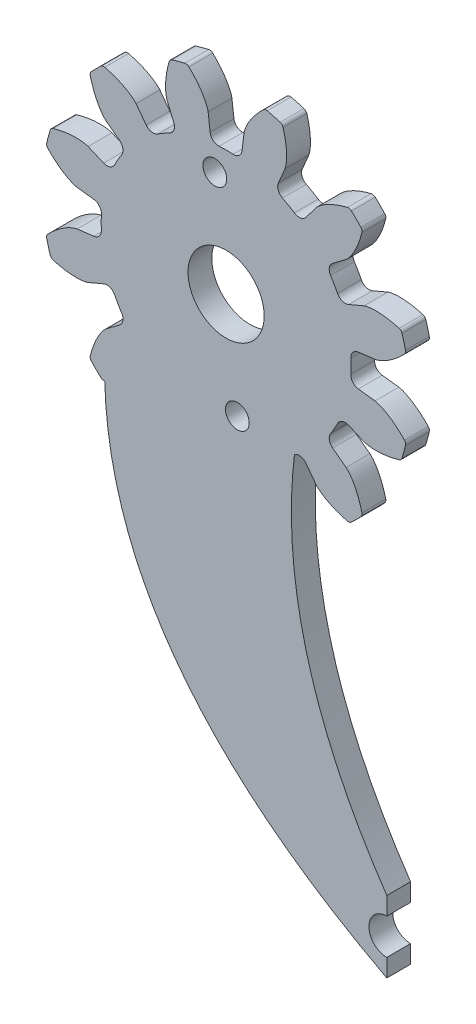
from build123d import *

# Parameters (mm, degrees)
SKETCH1_R                                 = 15.460869565
BOSS_EXTRUDE1_DEPTH                       = 2.00000108
CUT_EXTRUDE_DCLTBC_DEPTH                  = 3.00000108
FILLET_TIP_DCLTBC_R                       = 0.361402518
FILLET_ROOT_DCLTBC_R                      = 0.722805036
CIRPATTERN_DCLTBC_COUNT                   = 12
FILLET_TIP_DCLTBC_OF_CIRPATTERN_DCLTBC_R  = 0.361402518
FILLET_ROOT_DCLTBC_OF_CIRPATTERN_DCLTBC_R = 0.722805036
SKETCH5_R                                 = 3.1999936
SKETCH5_R_2                               = 1
CUT_EXTRUDE1_DEPTH                        = 2.000001
BOSS_EXTRUDE3_DEPTH                       = 2.000001
SKETCH11_R                                = 1.5
CUT_EXTRUDE2_DEPTH                        = 10.414
SKETCH12_R                                = 1
CUT_EXTRUDE3_DEPTH                        = 2.999994


with BuildPart() as part:
    # Sketch1 → Boss-Extrude1 (new body)
    with BuildSketch(Plane.XY):
        Circle(SKETCH1_R)
    extrude(amount=BOSS_EXTRUDE1_DEPTH)

    # DCLTBC → Cut-Extrude-DCLTBC (cut, through all)
    with BuildSketch(Plane.XY):
        with BuildLine():
            Line((-1.510543322, 12.512719278), (-1.257387732, 10.415682551))
            ThreePointArc((-1.257387732, 10.415682551), (0, 10.491304348), (1.257387732, 10.415682551))
            Line((1.257387732, 10.415682551), (1.510543322, 12.512719278))
            add(Edge.make_bspline(
                [(1.510543322, 12.512719278), (1.511807207, 12.52162806), (1.515924555, 12.546526961), (1.525964996, 12.593225704), (1.545522882, 12.668734363), (1.575075918, 12.763809525), (1.618532671, 12.885167967), (1.676416598, 13.025962467), (1.746944184, 13.178158407), (1.831019865, 13.340745724), (1.921301743, 13.500101292), (2.017222693, 13.656232464), (2.118001385, 13.809089493), (2.246130211, 13.990900958), (2.408119815, 14.204131446), (2.609271975, 14.445920176), (2.851094426, 14.710982591), (3.051394448, 14.910653016), (3.189156504, 15.040748908), (3.26165246, 15.107161264), (3.266741108, 15.111812937)],
                knots=[0, 0, 0, 0, 0, 0.005376748, 0.015083688, 0.02853182, 0.046610139, 0.064854849, 0.092110525, 0.119476175, 0.146842495, 0.174208853, 0.201574955, 0.228941013, 0.256307345, 0.307035032, 0.361767351, 0.41649966, 0.471231936, 0.475358859, 0.475358859, 0.475358859, 0.475358859, 0.475358859], degree=4))
            ThreePointArc((3.266741108, 15.111812937), (0, 15.460869565), (-3.266741108, 15.111812937))
            add(Edge.make_bspline(
                [(-1.510543322, 12.512719278), (-1.511807207, 12.52162806), (-1.515924555, 12.546526961), (-1.525964996, 12.593225704), (-1.545522882, 12.668734363), (-1.575075918, 12.763809525), (-1.618532671, 12.885167967), (-1.676416598, 13.025962467), (-1.746944184, 13.178158407), (-1.831019865, 13.340745724), (-1.921301743, 13.500101292), (-2.017222693, 13.656232464), (-2.118001385, 13.809089493), (-2.246130211, 13.990900958), (-2.408119815, 14.204131446), (-2.609271975, 14.445920176), (-2.851094426, 14.710982591), (-3.051394448, 14.910653016), (-3.189156504, 15.040748908), (-3.26165246, 15.107161264), (-3.266741108, 15.111812937)],
                knots=[0, 0, 0, 0, 0, 0.005376748, 0.015083688, 0.02853182, 0.046610139, 0.064854849, 0.092110525, 0.119476175, 0.146842495, 0.174208853, 0.201574955, 0.228941013, 0.256307345, 0.307035032, 0.361767351, 0.41649966, 0.471231936, 0.475358859, 0.475358859, 0.475358859, 0.475358859, 0.475358859], degree=4))
        make_face()
    cut_extrude_dcltbc = extrude(amount=CUT_EXTRUDE_DCLTBC_DEPTH, mode=Mode.SUBTRACT)

    # Fillet-Tip-DCLTBC
    fillet_tip_dcltbc_edges = [part.edges().sort_by_distance(p)[0] for p in [
        (3.266741108, 15.111812937, 1.00000054),
        (-3.266741108, 15.111812937, 1.00000054),
    ]]
    fillet(fillet_tip_dcltbc_edges, radius=FILLET_TIP_DCLTBC_R)

    # Fillet-Root-DCLTBC
    fillet_root_dcltbc_edges = [part.edges().sort_by_distance(p)[0] for p in [
        (1.257387732, 10.415682551, 1.00000054),
        (-1.257387732, 10.415682551, 1.00000054),
    ]]
    fillet(fillet_root_dcltbc_edges, radius=FILLET_ROOT_DCLTBC_R)

    # CirPattern-DCLTBC: Cut-Extrude-DCLTBC ×12 about axis
    cirpattern_dcltbc_axis = Axis((0, 0, 2.00000108), (0, 0, 1))
    for i in range(1, CIRPATTERN_DCLTBC_COUNT):
        add(cut_extrude_dcltbc.rotate(cirpattern_dcltbc_axis, i * 360 / CIRPATTERN_DCLTBC_COUNT), mode=Mode.SUBTRACT)

    # Fillet-Tip-DCLTBC of CirPattern-DCLTBC
    fillet_tip_dcltbc_of_cirpattern_dcltbc_edges = [part.edges().sort_by_distance(p)[0] for p in [
        (-4.726825682, 14.720584455, 1.00000054),
        (-10.384987255, 11.453843347, 1.00000054),
        (-11.453843347, 10.384987255, 1.00000054),
        (-14.720584455, 4.726825682, 1.00000054),
        (-15.111812937, 3.266741108, 1.00000054),
        (-15.111812937, -3.266741108, 1.00000054),
        (-14.720584455, -4.726825682, 1.00000054),
        (-11.453843347, -10.384987255, 1.00000054),
        (-10.384987255, -11.453843347, 1.00000054),
        (-4.726825682, -14.720584455, 1.00000054),
        (-3.266741108, -15.111812937, 1.00000054),
        (3.266741108, -15.111812937, 1.00000054),
        (4.726825682, -14.720584455, 1.00000054),
        (10.384987255, -11.453843347, 1.00000054),
        (11.453843347, -10.384987255, 1.00000054),
        (14.720584455, -4.726825682, 1.00000054),
        (15.111812937, -3.266741108, 1.00000054),
        (15.111812937, 3.266741108, 1.00000054),
        (14.720584455, 4.726825682, 1.00000054),
        (11.453843347, 10.384987255, 1.00000054),
        (10.384987255, 11.453843347, 1.00000054),
        (4.726825682, 14.720584455, 1.00000054),
    ]]
    fillet(fillet_tip_dcltbc_of_cirpattern_dcltbc_edges, radius=FILLET_TIP_DCLTBC_OF_CIRPATTERN_DCLTBC_R)

    # Fillet-Root-DCLTBC of CirPattern-DCLTBC
    fillet_root_dcltbc_of_cirpattern_dcltbc_edges = [part.edges().sort_by_distance(p)[0] for p in [
        (-4.118911557, 9.648939553, 1.00000054),
        (-6.296770994, 8.391551821, 1.00000054),
        (-8.391551821, 6.296770994, 1.00000054),
        (-9.648939553, 4.118911557, 1.00000054),
        (-10.415682551, 1.257387732, 1.00000054),
        (-10.415682551, -1.257387732, 1.00000054),
        (-9.648939553, -4.118911557, 1.00000054),
        (-8.391551821, -6.296770994, 1.00000054),
        (-6.296770994, -8.391551821, 1.00000054),
        (-4.118911557, -9.648939553, 1.00000054),
        (-1.257387732, -10.415682551, 1.00000054),
        (1.257387732, -10.415682551, 1.00000054),
        (4.118911557, -9.648939553, 1.00000054),
        (6.296770994, -8.391551821, 1.00000054),
        (8.391551821, -6.296770994, 1.00000054),
        (9.648939553, -4.118911557, 1.00000054),
        (10.415682551, -1.257387732, 1.00000054),
        (10.415682551, 1.257387732, 1.00000054),
        (9.648939553, 4.118911557, 1.00000054),
        (8.391551821, 6.296770994, 1.00000054),
        (6.296770994, 8.391551821, 1.00000054),
        (4.118911557, 9.648939553, 1.00000054),
    ]]
    fillet(fillet_root_dcltbc_of_cirpattern_dcltbc_edges, radius=FILLET_ROOT_DCLTBC_OF_CIRPATTERN_DCLTBC_R)

    # Sketch5 → Cut-Extrude1 (cut)
    with BuildSketch(Plane.XY.offset(2.00000108)):
        Circle(SKETCH5_R)
        with Locations((-0.945919467, 8.396888493)):
            Circle(SKETCH5_R_2)
    extrude(amount=-CUT_EXTRUDE1_DEPTH, mode=Mode.SUBTRACT)

    # Sketch10 → Boss-Extrude3 (add, through all)
    with BuildSketch(Plane.XY.offset(2.00000108)):
        with BuildLine():
            Line((12.5, -40), (8.314238955, -40))
            add(Edge.make_bspline(
                [(13.5, -43), (10.747309369, -41.55064806), (8.314238955, -40)],
                knots=[0, 0, 0, 0.108217675, 0.108217675, 0.108217675], degree=2))
            Line((13.5, -43), (13.5, -41))
            ThreePointArc((13.5, -41), (12.792893219, -40.707106781), (12.5, -40))
        make_face()
        with BuildLine():
            Line((6.75, -3.459494776), (0, -5.105794891))
            Line((0, -5.105794891), (0, -33.528005487))
            add(Edge.make_bspline(
                [(8.314238955, -40), (3.542420073, -36.958817283), (0, -33.528005487)],
                knots=[0.108217675, 0.108217675, 0.108217675, 0.32045779, 0.32045779, 0.32045779], degree=2))
            Line((8.314238955, -40), (12.5, -40))
            ThreePointArc((12.5, -40), (12.792893219, -39.292893219), (13.5, -39))
            Line((13.5, -39), (13.5, -37))
            add(Edge.make_bspline(
                [(13.5, -37), (2.303322789, -20.547342829), (6.75, -3.459494776)],
                knots=[0, 0, 0, 1, 1, 1], degree=2))
        make_face()
        with BuildLine():
            Line((0, -33.528005487), (0, -5.105794891))
            Line((0, -5.105794891), (-10.081061105, -7.564528529))
            add(Edge.make_bspline(
                [(0, -33.528005487), (-11.341983909, -22.543364652), (-10.081061105, -7.564528529)],
                knots=[0.32045779, 0.32045779, 0.32045779, 1, 1, 1], degree=2))
        make_face()
    extrude(amount=-BOSS_EXTRUDE3_DEPTH)

    # Sketch11 → Cut-Extrude2 (cut)
    with BuildSketch(Plane.XY.offset(2.00000108)):
        with Locations((13.5, -40)):
            Circle(SKETCH11_R)
    extrude(amount=-CUT_EXTRUDE2_DEPTH, mode=Mode.SUBTRACT)

    # Sketch12 → Cut-Extrude3 (cut)
    with BuildSketch(Plane.XY.offset(2.00000108)):
        with Locations((0.945919467, -8.396888493)):
            Circle(SKETCH12_R)
    extrude(amount=-CUT_EXTRUDE3_DEPTH, mode=Mode.SUBTRACT)


solid = part.part
